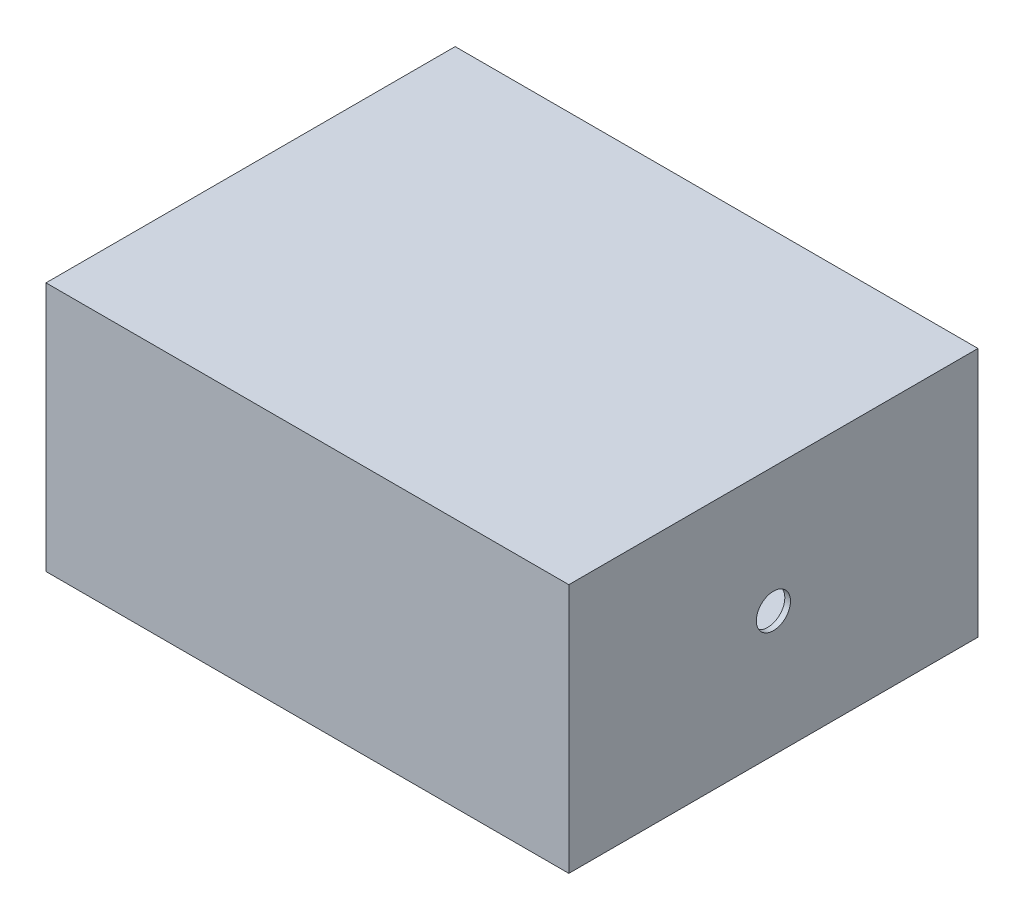
from build123d import *

# Parameters (mm, degrees)
SKETCH1_W           = 920
SKETCH1_H           = 720
BOSS_EXTRUDE1_DEPTH = 440
SHELL1_T            = 10
CUT_EXTRUDE1_REACH  = 922
SKETCH2_R           = 30.075332342


with BuildPart() as part:
    # Sketch1 → Boss-Extrude1 (new body)
    with BuildSketch(Plane(origin=(0, 0, 0), x_dir=(1, 0, 0), z_dir=(0, 1, 0))):
        Rectangle(SKETCH1_W, SKETCH1_H)
    extrude(amount=BOSS_EXTRUDE1_DEPTH)

    # Shell1 (no face opened: a closed hollow body)
    add(offset(amount=-SHELL1_T, mode=Mode.PRIVATE), mode=Mode.SUBTRACT)

    # Sketch2 → Cut-Extrude1 (cut, up to next)
    with BuildSketch(Plane(origin=(460, 0, 0), x_dir=(0, 0, -1), z_dir=(1, 0, 0)), mode=Mode.PRIVATE) as cut_extrude1_sk1:
        with Locations((0, 220)):
            Circle(SKETCH2_R)
    cut_extrude1_tool1 = extrude(cut_extrude1_sk1.sketch, amount=-CUT_EXTRUDE1_REACH, mode=Mode.PRIVATE) & part.part
    add(cut_extrude1_tool1.solids().sort_by_distance((460, 220, 0))[0], mode=Mode.SUBTRACT)


solid = part.part
